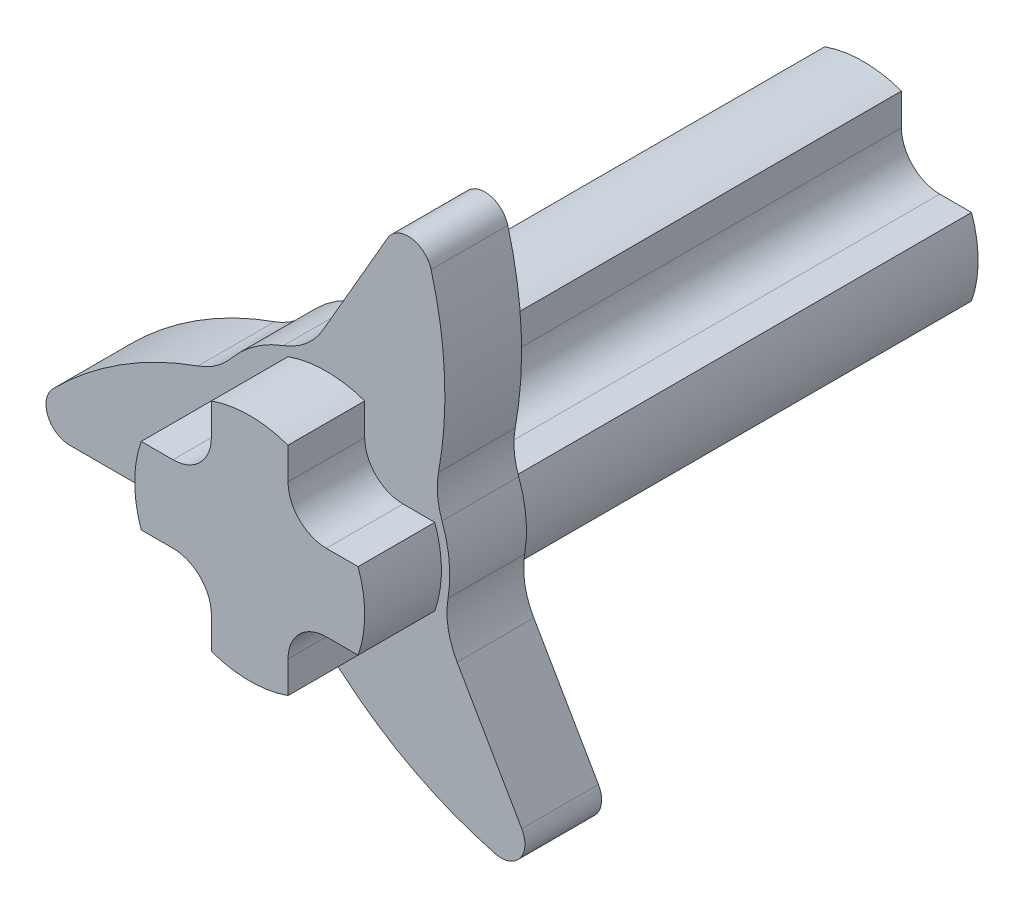
from build123d import *

# Parameters (mm, degrees)
BOSS_EXTRUDE1_DEPTH = 600
CIRPATTERN1_COUNT   = 4
FILLET1_R           = 50
SKETCH4_R           = 160
BOSS_EXTRUDE3_DEPTH = 100
BOSS_EXTRUDE2_DEPTH = 100
FILLET2_R           = 30
CIRPATTERN2_COUNT   = 3
FILLET4_R           = 100
EXTRUDE_THIN1_START = -100
EXTRUDE_THIN1_DEPTH = 100
BOSS_EXTRUDE4_START = 700
BOSS_EXTRUDE4_DEPTH = 100
CIRPATTERN3_COUNT   = 4
FILLET3_R           = 50


with BuildPart() as part:
    # Sketch1 → Boss-Extrude1 (new body)
    with BuildSketch(Plane(origin=(0, 0, 0), x_dir=(0, 1, 0), z_dir=(0, 0, 1))):
        with BuildLine():
            Line((-50, 141.421356237), (-50, 0))
            Line((-50, 0), (50, 0))
            Line((50, 0), (50, 141.421356237))
            ThreePointArc((50, 141.421356237), (0, 150), (-50, 141.421356237))
        make_face()
    extrude(amount=BOSS_EXTRUDE1_DEPTH)


with BuildPart() as cirpattern1_1:
    # CirPattern1: pattern copy
    add(part.part.rotate(Axis((0, 0, 0), (0, 0, 1)), 1 * 360 / CIRPATTERN1_COUNT))


with BuildPart() as cirpattern1_2:
    # CirPattern1: pattern copy
    add(part.part.rotate(Axis((0, 0, 0), (0, 0, 1)), 2 * 360 / CIRPATTERN1_COUNT))


with BuildPart() as cirpattern1_3:
    # CirPattern1: pattern copy
    add(part.part.rotate(Axis((0, 0, 0), (0, 0, 1)), 3 * 360 / CIRPATTERN1_COUNT))


with BuildPart() as part_1:
    add(part.part)

    # Combine1: union CirPattern1_1, CirPattern1_2, CirPattern1_3
    add(cirpattern1_1.part)
    add(cirpattern1_2.part)
    add(cirpattern1_3.part)

    # Fillet1
    fillet1_edges = [part_1.edges().sort_by_distance(p)[0] for p in [
        (-50, 50, 300),
        (-50, -50, 300),
        (50, -50, 300),
        (50, 50, 300),
    ]]
    fillet(fillet1_edges, radius=FILLET1_R)

    # Sketch4 → Boss-Extrude3 (add)
    with BuildSketch(Plane(origin=(0, 0, 600), x_dir=(0, 1, 0), z_dir=(0, 0, 1))):
        Circle(SKETCH4_R)
    extrude(amount=BOSS_EXTRUDE3_DEPTH)


with BuildPart() as body_2:
    # Sketch3 → Boss-Extrude2 (new body)
    with BuildSketch(Plane(origin=(0, 0, 600), x_dir=(0, 1, 0), z_dir=(0, 0, 1))):
        with BuildLine():
            Line((-100, 0), (-100, 400))
            ThreePointArc((-100, 400), (47.2135955, 223.60679775), (100, 0))
            Line((100, 0), (-100, 0))
        make_face()
    extrude(amount=BOSS_EXTRUDE2_DEPTH)

    # Fillet2
    fillet2_edges = [body_2.edges().sort_by_distance(p)[0] for p in [
        (-400, -100, 650),
    ]]
    fillet(fillet2_edges, radius=FILLET2_R)


with BuildPart() as cirpattern2_1:
    # CirPattern2: pattern copy
    add(body_2.part.rotate(Axis((0, 0, 0), (0, 0, 1)), 1 * 360 / CIRPATTERN2_COUNT))


with BuildPart() as cirpattern2_2:
    # CirPattern2: pattern copy
    add(body_2.part.rotate(Axis((0, 0, 0), (0, 0, 1)), 2 * 360 / CIRPATTERN2_COUNT))


with BuildPart() as part_2:
    add(part_1.part)

    # Combine2: union body 2, CirPattern2_2, CirPattern2_1
    add(body_2.part)
    add(cirpattern2_2.part)
    add(cirpattern2_1.part)

    # Fillet4
    fillet4_edges = [part_2.edges().sort_by_distance(p)[0] for p in [
        (-138.274184142, 80.5, 650),
        (-124.899959968, -100, 650),
        (-24.152560394, 158.166538264, 650),
        (-0.577952934, -159.998956154, 650),
        (138.852137075, 79.498956154, 650),
        (149.052520362, -58.166538264, 650),
    ]]
    fillet(fillet4_edges, radius=FILLET4_R)

    # Sketch5 → Extrude-Thin1 (add)
    with BuildSketch(Plane(origin=(0, 0, 700), x_dir=(0, 1, 0), z_dir=(0, 0, 1)).offset(EXTRUDE_THIN1_START)):
        with BuildLine():
            Line((-101, 334.664010614), (-101, 166.132477258))
            ThreePointArc((-101, 166.132477258), (-106.886545631, 132.503849344), (-123.846153846, 102.874341687))
            ThreePointArc((-123.846153846, 102.874341687), (-146.358154113, 67.084206225), (-158.776100224, 26.667395777))
            ThreePointArc((-158.776100224, 26.667395777), (-166.687757285, 1.218391324), (-181.101188564, -21.198101351))
            ThreePointArc((-181.101188564, -21.198101351), (-244.243580866, -114.788399022), (-284.826797866, -220.140703324))
            ThreePointArc((-284.826797866, -220.140703324), (-273.61273561, -252.61379645), (-239.327534924, -254.800571089))
            Line((-239.327534924, -254.800571089), (-93.374945699, -170.534804411))
            ThreePointArc((-93.374945699, -170.534804411), (-61.308426816, -158.818388511), (-27.168716375, -158.691086235))
            ThreePointArc((-27.168716375, -158.691086235), (15.082450273, -160.291982625), (56.293407917, -150.837834197))
            ThreePointArc((56.293407917, -150.837834197), (82.288720804, -144.965027971), (108.908688564, -146.239179276))
            ThreePointArc((108.908688564, -146.239179276), (221.531460046, -154.12694623), (333.060840419, -136.596890968))
            ThreePointArc((333.060840419, -136.596890968), (355.576332877, -110.648681612), (340.327534924, -79.863439525))
            Line((340.327534924, -79.863439525), (194.374945699, 4.402327153))
            ThreePointArc((194.374945699, 4.402327153), (168.194972447, 26.314539167), (151.014870222, 55.816744548))
            ThreePointArc((151.014870222, 55.816744548), (131.275703839, 93.2077764), (102.482692308, 124.17043842))
            ThreePointArc((102.482692308, 124.17043842), (84.399036481, 143.746636647), (72.1925, 167.437280627))
            ThreePointArc((72.1925, 167.437280627), (22.71212082, 268.915345252), (-48.234042553, 356.737594292))
            ThreePointArc((-48.234042553, 356.737594292), (-81.963597267, 363.262478063), (-101, 334.664010614))
        make_face()
        with BuildLine():
            Line((-100, 334.664010614), (-100, 166.132477258))
            ThreePointArc((-100, 166.132477258), (-105.946005687, 132.164166234), (-123.076923077, 102.235370621))
            ThreePointArc((-123.076923077, 102.235370621), (-145.449097255, 66.667534136), (-157.789913267, 26.501759778))
            ThreePointArc((-157.789913267, 26.501759778), (-165.781486055, 0.795694675), (-180.340507548, -21.847227219))
            ThreePointArc((-180.340507548, -21.847227219), (-243.356867131, -115.250717909), (-283.859079706, -220.392738171))
            ThreePointArc((-283.859079706, -220.392738171), (-273.006761394, -251.818312164), (-239.827534924, -253.934545685))
            Line((-239.827534924, -253.934545685), (-93.874945699, -169.668779008))
            ThreePointArc((-93.874945699, -169.668779008), (-61.484522585, -157.834015472), (-26.999966584, -157.705427315))
            ThreePointArc((-26.999966584, -157.705427315), (14.988770458, -159.296380248), (55.94375942, -149.900953239))
            ThreePointArc((55.94375942, -149.900953239), (82.201651226, -143.968825738), (109.090507548, -145.255847259))
            ThreePointArc((109.090507548, -145.255847259), (221.48848308, -153.127870166), (332.795249919, -135.632805035))
            ThreePointArc((332.795249919, -135.632805035), (354.584436169, -110.521634691), (339.827534924, -80.729464928))
            Line((339.827534924, -80.729464928), (193.874945699, 3.536301749))
            ThreePointArc((193.874945699, 3.536301749), (167.430528272, 25.669849238), (150.076889661, 55.470056694))
            ThreePointArc((150.076889661, 55.470056694), (130.460326797, 92.628846112), (101.846153846, 123.399193461))
            ThreePointArc((101.846153846, 123.399193461), (83.57983483, 143.173131064), (71.25, 167.103074478))
            ThreePointArc((71.25, 167.103074478), (21.868384052, 268.378588076), (-48.936170213, 356.025543206))
            ThreePointArc((-48.936170213, 356.025543206), (-81.577674775, 362.339946854), (-100, 334.664010614))
        make_face(mode=Mode.SUBTRACT)
    extrude(amount=EXTRUDE_THIN1_DEPTH)


with BuildPart() as body_2_2:
    # Sketch1_3 → Boss-Extrude4 (new body)
    with BuildSketch(Plane(origin=(0, 0, 0), x_dir=(0, 1, 0), z_dir=(0, 0, 1)).offset(BOSS_EXTRUDE4_START)):
        with BuildLine():
            Line((-50, 141.421356237), (-50, 0))
            Line((-50, 0), (50, 0))
            Line((50, 0), (50, 141.421356237))
            ThreePointArc((50, 141.421356237), (0, 150), (-50, 141.421356237))
        make_face()
    extrude(amount=BOSS_EXTRUDE4_DEPTH)


with BuildPart() as cirpattern3_1:
    # CirPattern3: pattern copy
    add(body_2_2.part.rotate(Axis((0, 0, 0), (0, 0, 1)), 1 * 360 / CIRPATTERN3_COUNT))


with BuildPart() as cirpattern3_2:
    # CirPattern3: pattern copy
    add(body_2_2.part.rotate(Axis((0, 0, 0), (0, 0, 1)), 2 * 360 / CIRPATTERN3_COUNT))


with BuildPart() as cirpattern3_3:
    # CirPattern3: pattern copy
    add(body_2_2.part.rotate(Axis((0, 0, 0), (0, 0, 1)), 3 * 360 / CIRPATTERN3_COUNT))


with BuildPart() as body_2_2_1:
    add(body_2_2.part)

    # Combine3: union CirPattern3_3, CirPattern3_1, CirPattern3_2
    add(cirpattern3_3.part)
    add(cirpattern3_1.part)
    add(cirpattern3_2.part)

    # Fillet3
    fillet3_edges = [body_2_2_1.edges().sort_by_distance(p)[0] for p in [
        (-50, 50, 750),
        (-50, -50, 750),
        (50, 50, 750),
        (50, -50, 750),
    ]]
    fillet(fillet3_edges, radius=FILLET3_R)


solid = Compound([part_2.part, body_2_2_1.part])
